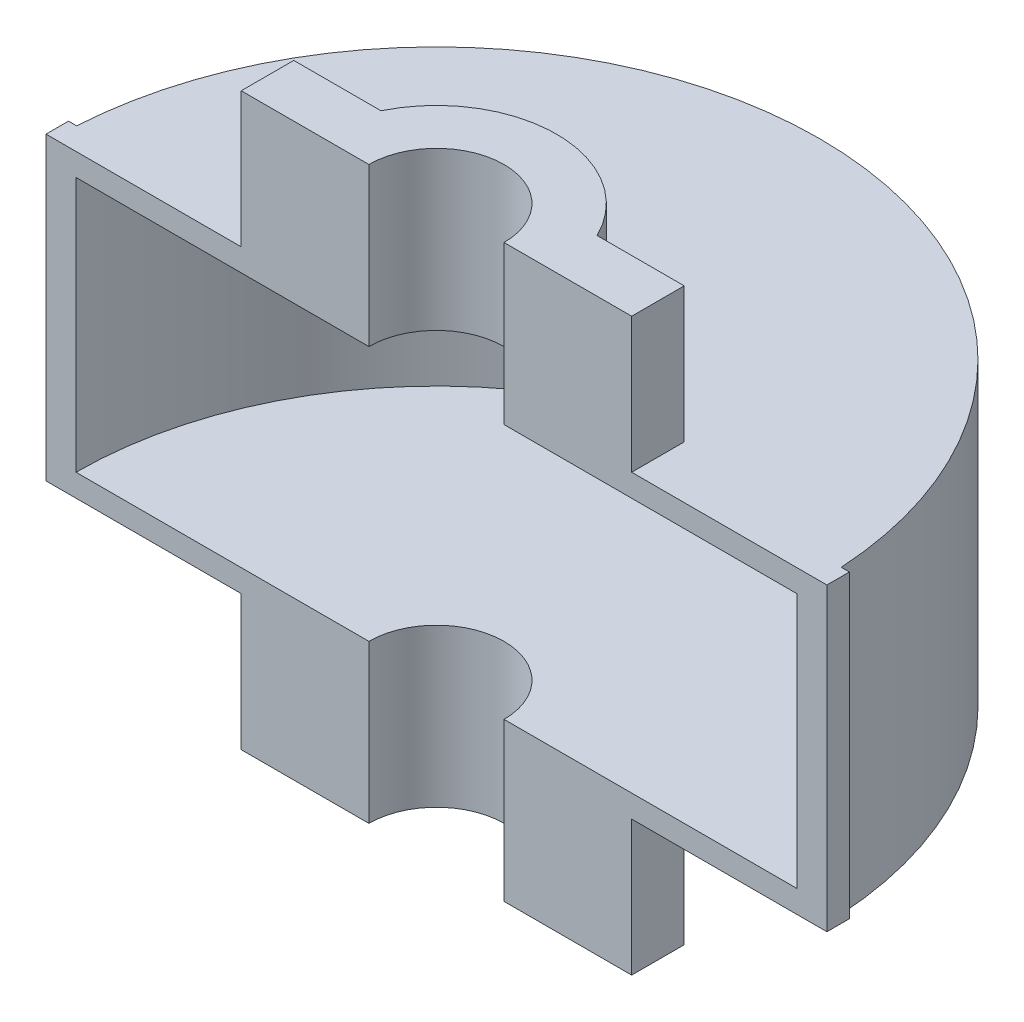
from build123d import *

# Parameters (mm, degrees)
REVOLVE1_ANGLE          = 180
SKETCH3_W               = 9
SKETCH3_H               = 120
BOSS_EXTRUDE3_DEPTH     = 3.264935
BOSS_EXTRUDE4_REACH     = 158
SKETCH6_R               = 27
SKETCH6_R_2             = 18
SKETCH7_R               = 18
CUT_EXTRUDE1_DEPTH      = 157
BOSS_EXTRUDE5_DEPTH     = 54
CUT_EXTRUDE2_DEPTH      = 175.0000001
CUT_EXTRUDE2_DEPTH_BACK = 1


with BuildPart() as part:
    # Sketch1 → Revolve1 (revolve)
    with BuildSketch(Plane.XY):
        Polygon((144, 9), (144, 111), (0, 111), (0, 120), (153, 120), (153, 0), (0, 0), (0, 9), align=None)
    revolve(axis=Axis((0, 0, 0), (0, 1, 0)), revolution_arc=REVOLVE1_ANGLE)

    # Sketch3 → Boss-Extrude3 (add)
    with BuildSketch(Plane(origin=(156, 0, 0), x_dir=(0, 0, -1), z_dir=(1, 0, 0))):
        with Locations((4.5, 60)):
            Rectangle(SKETCH3_W, SKETCH3_H)
    boss_extrude3 = extrude(amount=-BOSS_EXTRUDE3_DEPTH)

    # Mirror4: Boss-Extrude3 across plane
    add(boss_extrude3.mirror(Plane(origin=(0, 0, 0), x_dir=(0, 0, 1), z_dir=(1, 0, 0))))

    # Sketch6 → Boss-Extrude4 (add, up to next)
    with BuildSketch(Plane(origin=(0, 0, -156), x_dir=(-1, 0, 0), z_dir=(0, 0, -1)), mode=Mode.PRIVATE) as boss_extrude4_sk1:
        with Locations((0, 60)):
            Circle(SKETCH6_R)
        with Locations((0, 60)):
            Circle(SKETCH6_R_2, mode=Mode.SUBTRACT)
    boss_extrude4_tool1 = extrude(boss_extrude4_sk1.sketch, amount=-BOSS_EXTRUDE4_REACH, mode=Mode.PRIVATE) - part.part
    add(boss_extrude4_tool1.solids().sort_by_distance((26.236325, 60, -156))[0])

    # Sketch7 → Cut-Extrude1 (cut, through all)
    with BuildSketch(Plane(origin=(0, 0, -156), x_dir=(-1, 0, 0), z_dir=(0, 0, -1))):
        with Locations((0, 60)):
            Circle(SKETCH7_R)
    extrude(amount=-CUT_EXTRUDE1_DEPTH, mode=Mode.SUBTRACT)

    # Sketch8 → Boss-Extrude5 (add)
    with BuildSketch(Plane(origin=(0, -54, 0), x_dir=(1, 0, 0), z_dir=(0, 1, 0))):
        with BuildLine():
            Line((78, 0), (27, 0))
            ThreePointArc((27, 0), (0, 27), (-27, 0))
            Line((-27, 0), (-78, 0))
            Line((-78, 0), (-78, 21))
            Line((-78, 21), (-43.16248371, 21))
            ThreePointArc((-43.16248371, 21), (0, 48), (43.16248371, 21))
            Line((43.16248371, 21), (78, 21))
            Line((78, 21), (78, 0))
        make_face()
    boss_extrude5 = extrude(amount=BOSS_EXTRUDE5_DEPTH)

    # Sketch9 → Cut-Extrude2 (cut, two sides)
    with BuildSketch(Plane(origin=(0, -54, 0), x_dir=(1, 0, 0), z_dir=(0, 1, 0))) as cut_extrude2_sk:
        with BuildLine():
            Line((27, -490.936586386), (27, 0))
            ThreePointArc((27, 0), (0, 27), (-27, 0))
            Line((-27, 0), (-27, -490.936586386))
            Line((-27, -490.936586386), (-27, -1472.809759159))
            Line((-27, -1472.809759159), (27, -1472.809759159))
            Line((27, -1472.809759159), (27, -490.936586386))
        make_face()
    extrude(amount=CUT_EXTRUDE2_DEPTH, mode=Mode.SUBTRACT)
    extrude(cut_extrude2_sk.sketch, amount=-CUT_EXTRUDE2_DEPTH_BACK, mode=Mode.SUBTRACT)

    # Mirror6: Boss-Extrude5 across plane
    add(boss_extrude5.mirror(Plane.ZX.offset(60)))


solid = part.part
